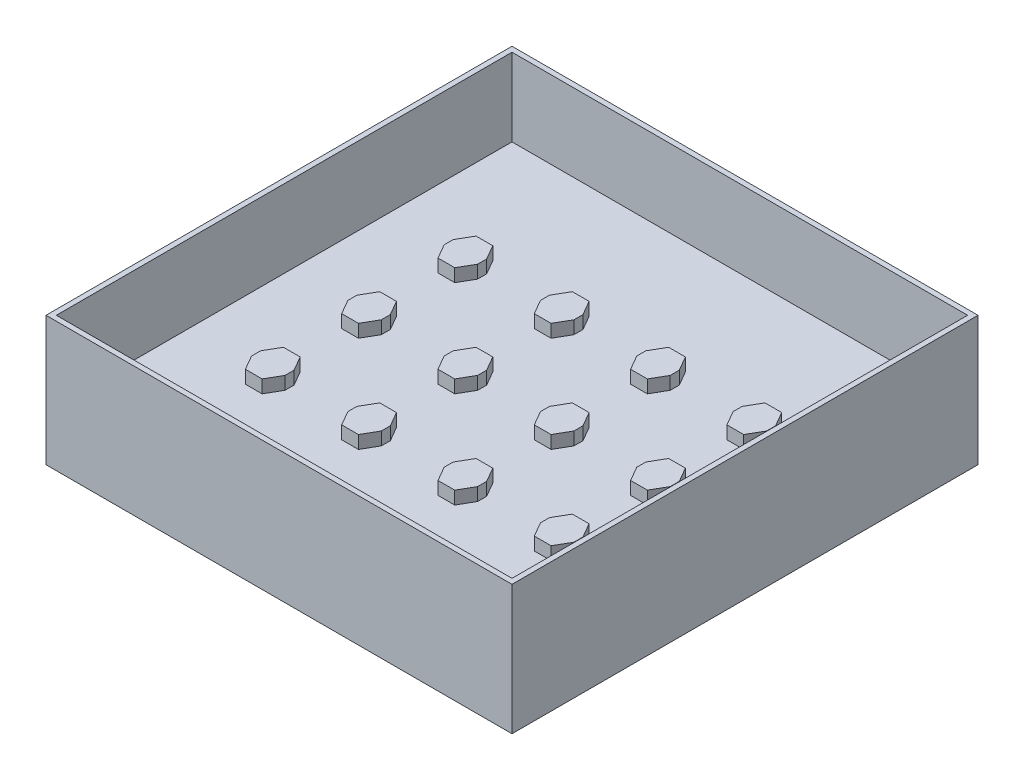
from build123d import *

# Parameters (mm, degrees)
SKETCH1_W                = 90
SKETCH1_H                = 90
BOSS_EXTRUDE1_DEPTH      = 3
BOSS_EXTRUDE3_DEPTH      = 2.5
SKETCH6_W                = 90
SKETCH6_H                = 90
SKETCH6_W_2              = 88
SKETCH6_H_2              = 88
BOSS_EXTRUDE4_DEPTH      = 15
BOSS_EXTRUDE4_DEPTH_BACK = 10


with BuildPart() as part:
    # Sketch1 → Boss-Extrude1 (new body)
    with BuildSketch(Plane(origin=(0, 0, 0), x_dir=(1, 0, 0), z_dir=(0, 1, 0))):
        Rectangle(SKETCH1_W, SKETCH1_H)
    extrude(amount=BOSS_EXTRUDE1_DEPTH)

    # Sketch4 → Boss-Extrude3 (add)
    with BuildSketch(Plane(origin=(0, 3, 0), x_dir=(1, 0, 0), z_dir=(0, 1, 0))):
        Polygon((6.366838491, 0.875), (6.366838491, -0.875), (7.983419247, -3.675000002), (11.216580757, -3.675000001), (12.833161509, -0.875), (12.833161509, 0), (12.833161509, 0.875), (11.216580757, 3.675000001), (7.983419247, 3.675000002), align=None)
        Polygon((6.366838491, 19.475), (6.366838491, 17.725), (7.983419247, 14.924999998), (11.216580757, 14.924999999), (12.833161509, 17.725), (12.833161509, 18.6), (12.833161509, 19.475), (11.216580757, 22.275000001), (7.983419247, 22.275000002), align=None)
        Polygon((24.966838491, 0.875), (24.966838491, -0.875), (26.583419247, -3.675000002), (29.816580757, -3.675000001), (31.433161509, -0.875), (31.433161509, 0), (31.433161509, 0.875), (29.816580757, 3.675000001), (26.583419247, 3.675000002), align=None)
        Polygon((24.966838491, -17.725), (24.966838491, -19.475), (26.583419247, -22.275000002), (29.816580757, -22.275000001), (31.433161509, -19.475), (31.433161509, -18.6), (31.433161509, -17.725), (29.816580757, -14.924999999), (26.583419247, -14.924999998), align=None)
        Polygon((6.366838491, -17.725), (6.366838491, -19.475), (7.983419247, -22.275000002), (11.216580757, -22.275000001), (12.833161509, -19.475), (12.833161509, -18.6), (12.833161509, -17.725), (11.216580757, -14.924999999), (7.983419247, -14.924999998), align=None)
        Polygon((-30.833161509, 0.875), (-30.833161509, -0.875), (-29.216580753, -3.675000002), (-25.983419243, -3.675000001), (-24.366838491, -0.875), (-24.366838491, 0), (-24.366838491, 0.875), (-25.983419243, 3.675000001), (-29.216580753, 3.675000002), align=None)
        Polygon((-12.233161509, 0.875), (-12.233161509, -0.875), (-10.616580753, -3.675000002), (-7.383419243, -3.675000001), (-5.766838491, -0.875), (-5.766838491, 0), (-5.766838491, 0.875), (-7.383419243, 3.675000001), (-10.616580753, 3.675000002), align=None)
        Polygon((-12.233161509, -17.725), (-12.233161509, -19.475), (-10.616580753, -22.275000002), (-7.383419243, -22.275000001), (-5.766838491, -19.475), (-5.766838491, -18.6), (-5.766838491, -17.725), (-7.383419243, -14.924999999), (-10.616580753, -14.924999998), align=None)
        Polygon((-30.833161509, -17.725), (-30.833161509, -19.475), (-29.216580753, -22.275000002), (-25.983419243, -22.275000001), (-24.366838491, -19.475), (-24.366838491, -18.6), (-24.366838491, -17.725), (-25.983419243, -14.924999999), (-29.216580753, -14.924999998), align=None)
        Polygon((24.966838491, 19.475), (24.966838491, 17.725), (26.583419247, 14.924999998), (29.816580757, 14.924999999), (31.433161509, 17.725), (31.433161509, 18.6), (31.433161509, 19.475), (29.816580757, 22.275000001), (26.583419247, 22.275000002), align=None)
        Polygon((-30.833161509, 19.475), (-30.833161509, 17.725), (-29.216580753, 14.924999998), (-25.983419243, 14.924999999), (-24.366838491, 17.725), (-24.366838491, 18.6), (-24.366838491, 19.475), (-25.983419243, 22.275000001), (-29.216580753, 22.275000002), align=None)
        Polygon((-12.233161509, 19.475), (-12.233161509, 17.725), (-10.616580753, 14.924999998), (-7.383419243, 14.924999999), (-5.766838491, 17.725), (-5.766838491, 18.6), (-5.766838491, 19.475), (-7.383419243, 22.275000001), (-10.616580753, 22.275000002), align=None)
    extrude(amount=BOSS_EXTRUDE3_DEPTH)

    # Sketch6 → Boss-Extrude4 (add, two sides)
    with BuildSketch(Plane(origin=(0, 3, 0), x_dir=(1, 0, 0), z_dir=(0, 1, 0))) as boss_extrude4_sk:
        Rectangle(SKETCH6_W, SKETCH6_H)
        Rectangle(SKETCH6_W_2, SKETCH6_H_2, mode=Mode.SUBTRACT)
    extrude(amount=BOSS_EXTRUDE4_DEPTH)
    extrude(boss_extrude4_sk.sketch, amount=-BOSS_EXTRUDE4_DEPTH_BACK)


solid = part.part
